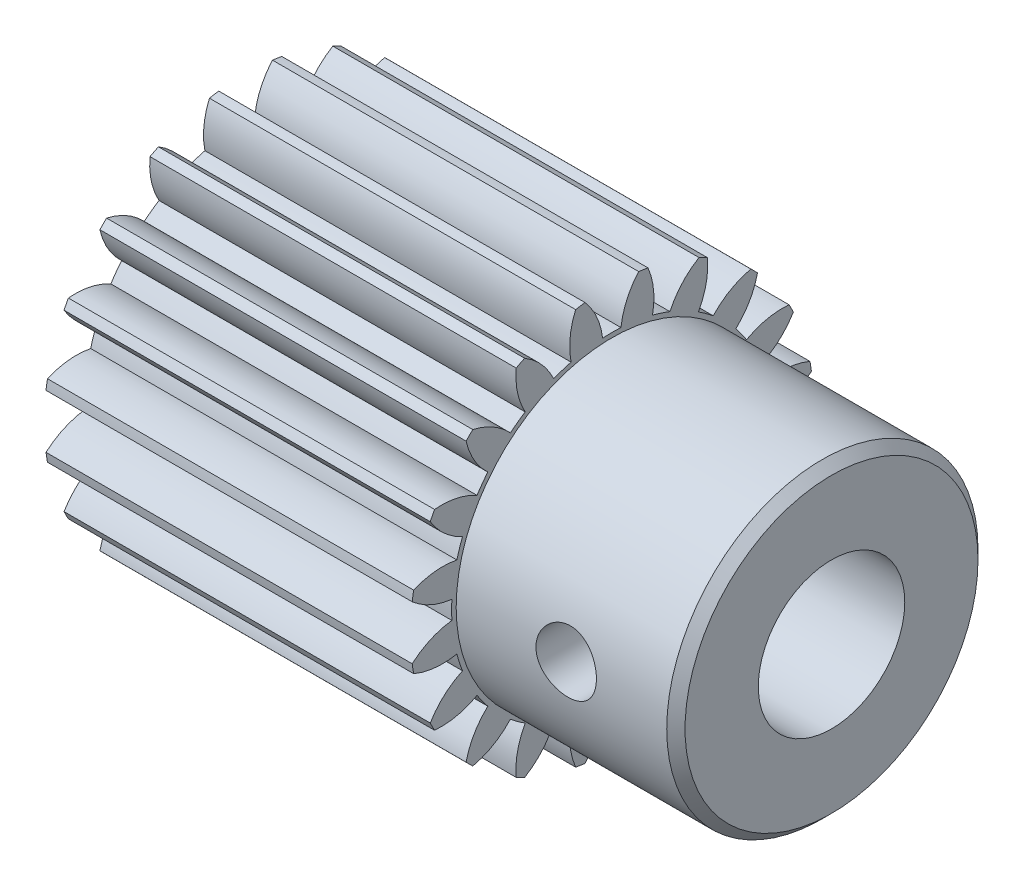
from build123d import *

# Parameters (mm, degrees)
BASPROSKE_W              = 20
BASPROSKE_H              = 11
TOOTHCUT_DEPTH           = 26.337718919
TEETHCUTS_COUNT          = 20
TEETHCUTS_ANGLE          = 342
SKETCH_2_R               = 8.5
EXTRUDE_1_DEPTH          = 12
BORSKE_R                 = 4
BORE_DEPTH               = 50.0000508
CHAMFER_1_SIZE           = 0.5
SKETCH_3_R               = 1.65
CUT_EXTRUDE_1_DEPTH      = 10
PATTERN_CIRCULAR_1_COUNT = 2
PATTERN_CIRCULAR_1_ANGLE = 90


with BuildPart() as part:
    # BasProSke → Base-Revolve (revolve)
    with BuildSketch(Plane(origin=(0, 0, 0), x_dir=(1, 0, 0), z_dir=(0, 1, 0)), mode=Mode.PRIVATE) as base_revolve_sk:
        with Locations((10, 5.5)):
            Rectangle(BASPROSKE_W, BASPROSKE_H)
    revolve(base_revolve_sk.sketch.rotate(Axis((-10, 0, 0), (1, 0, 0)), 180), axis=Axis((-10, 0, 0), (1, 0, 0)))

    # TooCutSke → ToothCut (cut, through all)
    with BuildSketch(Plane(origin=(0, 0, 0), x_dir=(0, 0, -1), z_dir=(1, 0, 0))):
        with BuildLine():
            ThreePointArc((0.499924007, 8.734705318), (0, 8.749), (-0.499924007, 8.734705318))
            ThreePointArc((-0.499924007, 8.734705318), (-0.824302243, 9.905497836), (-1.485192705, 10.924909509))
            ThreePointArc((-1.485192705, 10.924909509), (0, 11.0254), (1.485192705, 10.924909509))
            ThreePointArc((1.485192705, 10.924909509), (0.824302243, 9.905497836), (0.499924007, 8.734705318))
        make_face()
    toothcut = extrude(amount=TOOTHCUT_DEPTH, mode=Mode.SUBTRACT)

    # TeethCuts: ToothCut ×20 about axis
    teethcuts_axis = Axis((-10, 0, 0), (1, 0, 0))
    for i in range(1, TEETHCUTS_COUNT):
        add(toothcut.rotate(teethcuts_axis, i * TEETHCUTS_ANGLE / (TEETHCUTS_COUNT - 1)), mode=Mode.SUBTRACT)

    # 草圖2 → 填料-伸長1 (add)
    with BuildSketch(Plane(origin=(20, 0, 0), x_dir=(0, 0, -1), z_dir=(1, 0, 0))):
        with Locations(Location((0, 0, 0), (0, 0, 180))):
            Circle(SKETCH_2_R)
    extrude(amount=EXTRUDE_1_DEPTH)

    # BorSke → Bore (cut, symmetric)
    with BuildSketch(Plane(origin=(0, 0, 0), x_dir=(0, 0, -1), z_dir=(1, 0, 0))):
        Circle(BORSKE_R)
    extrude(amount=BORE_DEPTH, both=True, mode=Mode.SUBTRACT)

    # 導角1
    chamfer_1_edges = [part.edges().sort_by_distance(p)[0] for p in [
        (32, 0, -8.5),
    ]]
    chamfer(chamfer_1_edges, length=CHAMFER_1_SIZE)

    # 草圖3 → 除料-伸長1 (cut)
    with BuildSketch(Plane(origin=(0, 0, 0), x_dir=(1, 0, 0), z_dir=(0, 1, 0))):
        with Locations(Location((26, -0.356131442, 0), (0, 0, 270))):
            Circle(SKETCH_3_R)
    cut_extrude_1 = extrude(amount=-CUT_EXTRUDE_1_DEPTH, mode=Mode.SUBTRACT)

    # 環狀複製排列1: 除料-伸長1 ×2 about axis
    pattern_circular_1_axis = Axis((32, 0, 0), (-1, 0, 0))
    for i in range(1, PATTERN_CIRCULAR_1_COUNT):
        add(cut_extrude_1.rotate(pattern_circular_1_axis, i * PATTERN_CIRCULAR_1_ANGLE / (PATTERN_CIRCULAR_1_COUNT - 1)), mode=Mode.SUBTRACT)


solid = part.part
